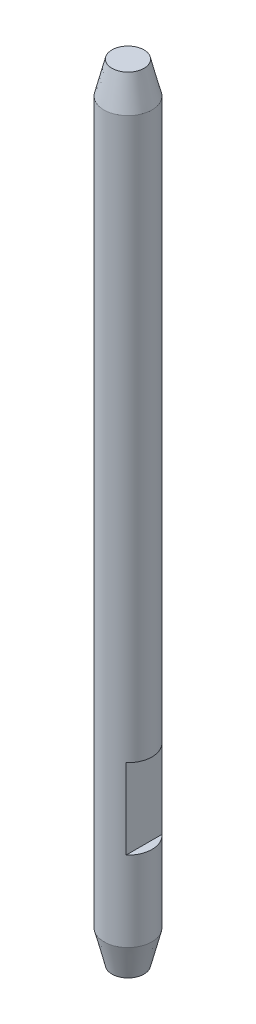
from build123d import *

# Parameters (mm, degrees)
SKETCH1_R           = 1.5
BOSS_EXTRUDE1_DEPTH = 49
CHAMFER1_SIZE       = 0.5
CHAMFER1_SIZE2      = 2
CHAMFER2_SIZE       = 2
CHAMFER2_SIZE2      = 0.5
SKETCH2_W           = 6
SKETCH2_H           = 5
CUT_EXTRUDE1_DEPTH  = 0.5


with BuildPart() as part:
    # Sketch1 → Boss-Extrude1 (new body)
    with BuildSketch(Plane(origin=(0, 0, 0), x_dir=(1, 0, 0), z_dir=(0, 1, 0))):
        Circle(SKETCH1_R)
    extrude(amount=BOSS_EXTRUDE1_DEPTH)

    # Chamfer1
    chamfer1_edges = [part.edges().sort_by_distance(p)[0] for p in [
        (-1.5, 0, 0),
    ]]
    chamfer1_side = [part.faces().sort_by_distance(p)[0] for p in [
        (0, 0, 0),
    ]]
    chamfer(chamfer1_edges, length=CHAMFER1_SIZE, length2=CHAMFER1_SIZE2, reference=chamfer1_side[0])

    # Chamfer2
    chamfer2_edges = [part.edges().sort_by_distance(p)[0] for p in [
        (-1.5, 49, 0),
    ]]
    chamfer2_side = [part.faces().sort_by_distance(p)[0] for p in [
        (-1.5, 25.5, 0),
    ]]
    chamfer(chamfer2_edges, length=CHAMFER2_SIZE, length2=CHAMFER2_SIZE2, reference=chamfer2_side[0])

    # Sketch2 → Cut-Extrude1 (cut)
    with BuildSketch(Plane(origin=(1.5, 0, 0), x_dir=(0, 0, -1), z_dir=(1, 0, 0))):
        with Locations((0, 9.5)):
            Rectangle(SKETCH2_W, SKETCH2_H)
    extrude(amount=-CUT_EXTRUDE1_DEPTH, mode=Mode.SUBTRACT)


solid = part.part
